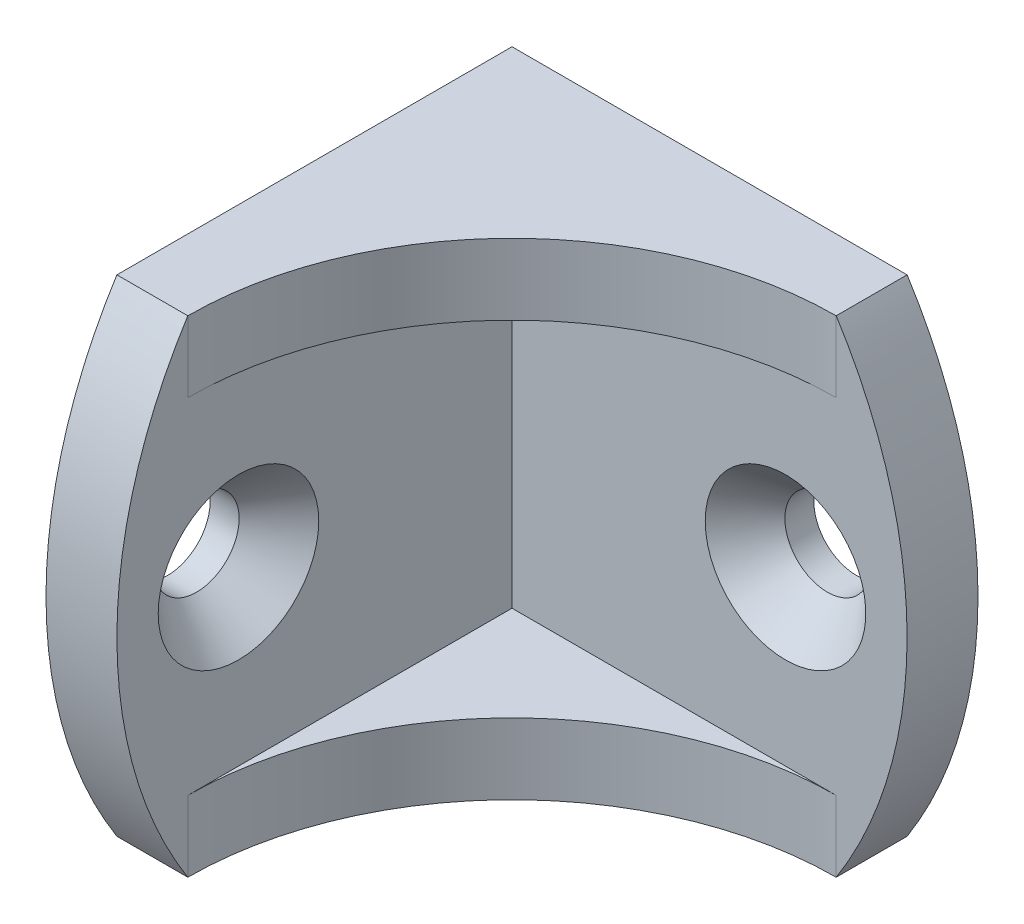
from build123d import *

# Parameters (mm, degrees)
BOSS_EXTRUDE1_DEPTH          = 12
BOSS_EXTRUDE1_DEPTH_BACK     = 12
BOSS_EXTRUDE2_DEPTH          = 3.5
CUT_EXTRUDE3_START           = -4.5
CUT_EXTRUDE3_DEPTH           = 25
CUT_EXTRUDE1_START           = -4.5
SKETCH5_R                    = 2.1
CUT_EXTRUDE1_DEPTH           = 25
SKETCH6_R                    = 3.9624
CUT_EXTRUDE2_DEPTH           = 3.5
CUT_EXTRUDE2_TAPER           = 42
CUT_EXTRUDE2_OTHER_WAY_DEPTH = 3.048
CUT_EXTRUDE2_OTHER_WAY_TAPER = 42
CIRPATTERN2_COUNT            = 2
CIRPATTERN2_ANGLE            = 180


with BuildPart() as part:
    # Sketch3 → Boss-Extrude1 (new body, two sides)
    with BuildSketch(Plane(origin=(0, 0, 0), x_dir=(1, 0, 0), z_dir=(0, 1, 0))) as boss_extrude1_sk:
        Polygon((0, -23), (3.5, -23), (3.5, -3.5), (23, -3.5), (23, 0), (0, 0), align=None)
    extrude(amount=BOSS_EXTRUDE1_DEPTH)
    extrude(boss_extrude1_sk.sketch, amount=-BOSS_EXTRUDE1_DEPTH_BACK)

    # Sketch8 → Boss-Extrude2 (add)
    with BuildSketch(Plane(origin=(0, 12, 0), x_dir=(1, 0, 0), z_dir=(0, 1, 0))):
        with BuildLine():
            Line((3.5, -3.5), (19.5, -3.5))
            ThreePointArc((19.5, -3.5), (8.186291501, -8.186291501), (3.5, -19.5))
            Line((3.5, -19.5), (3.5, -3.5))
        make_face()
    boss_extrude2 = extrude(amount=-BOSS_EXTRUDE2_DEPTH)

    # Mirror1: Boss-Extrude2 across plane
    add(boss_extrude2.mirror(Plane.ZX))

    # Sketch7 → Cut-Extrude3 (cut)
    with BuildSketch(Plane(origin=(3.5, 0, 0), x_dir=(0, 0, -1), z_dir=(1, 0, 0)).offset(CUT_EXTRUDE3_START)):
        with BuildLine():
            Line((19.124723765, 72.581039953), (-19.5, 12))
            ThreePointArc((-19.5, 12), (-23, 0), (-19.5, -12))
            Line((-19.5, -12), (19.124723765, -72.581039953))
            Line((19.124723765, -72.581039953), (-124.568445004, -72.581039953))
            Line((-124.568445004, -72.581039953), (-124.568445004, 72.581039953))
            Line((-124.568445004, 72.581039953), (19.124723765, 72.581039953))
        make_face()
    cut_extrude3 = extrude(amount=CUT_EXTRUDE3_DEPTH, mode=Mode.SUBTRACT)

    # Sketch5 → Cut-Extrude1 (cut)
    with BuildSketch(Plane(origin=(3.5, 0, 0), x_dir=(0, 0, -1), z_dir=(1, 0, 0)).offset(CUT_EXTRUDE1_START)):
        with Locations((-17, 0)):
            Circle(SKETCH5_R)
    cut_extrude1 = extrude(amount=CUT_EXTRUDE1_DEPTH, mode=Mode.SUBTRACT)

    # Sketch6 → Cut-Extrude2 (cut)
    with BuildSketch(Plane(origin=(3.5, 0, 0), x_dir=(0, 0, -1), z_dir=(1, 0, 0))):
        with Locations((-17, 0)):
            Circle(SKETCH6_R)
    cut_extrude2 = extrude(amount=-CUT_EXTRUDE2_DEPTH, taper=CUT_EXTRUDE2_TAPER, mode=Mode.SUBTRACT)

    # Sketch6 → Cut-Extrude2 other way (cut)
    with BuildSketch(Plane(origin=(3.5, 0, 0), x_dir=(0, 0, -1), z_dir=(1, 0, 0))):
        with Locations((-17, 0)):
            Circle(SKETCH6_R)
    extrude(amount=CUT_EXTRUDE2_OTHER_WAY_DEPTH, taper=CUT_EXTRUDE2_OTHER_WAY_TAPER, mode=Mode.SUBTRACT)

    # CirPattern2: Cut-Extrude3, Cut-Extrude1, Cut-Extrude2 ×2 about axis
    cirpattern2_axis = Axis((0, 0, 0), (0.707106781, 0, 0.707106781))
    for i in range(1, CIRPATTERN2_COUNT):
        add(cut_extrude3.rotate(cirpattern2_axis, i * CIRPATTERN2_ANGLE / (CIRPATTERN2_COUNT - 1)), mode=Mode.SUBTRACT)
        add(cut_extrude1.rotate(cirpattern2_axis, i * CIRPATTERN2_ANGLE / (CIRPATTERN2_COUNT - 1)), mode=Mode.SUBTRACT)
        add(cut_extrude2.rotate(cirpattern2_axis, i * CIRPATTERN2_ANGLE / (CIRPATTERN2_COUNT - 1)), mode=Mode.SUBTRACT)


solid = part.part
